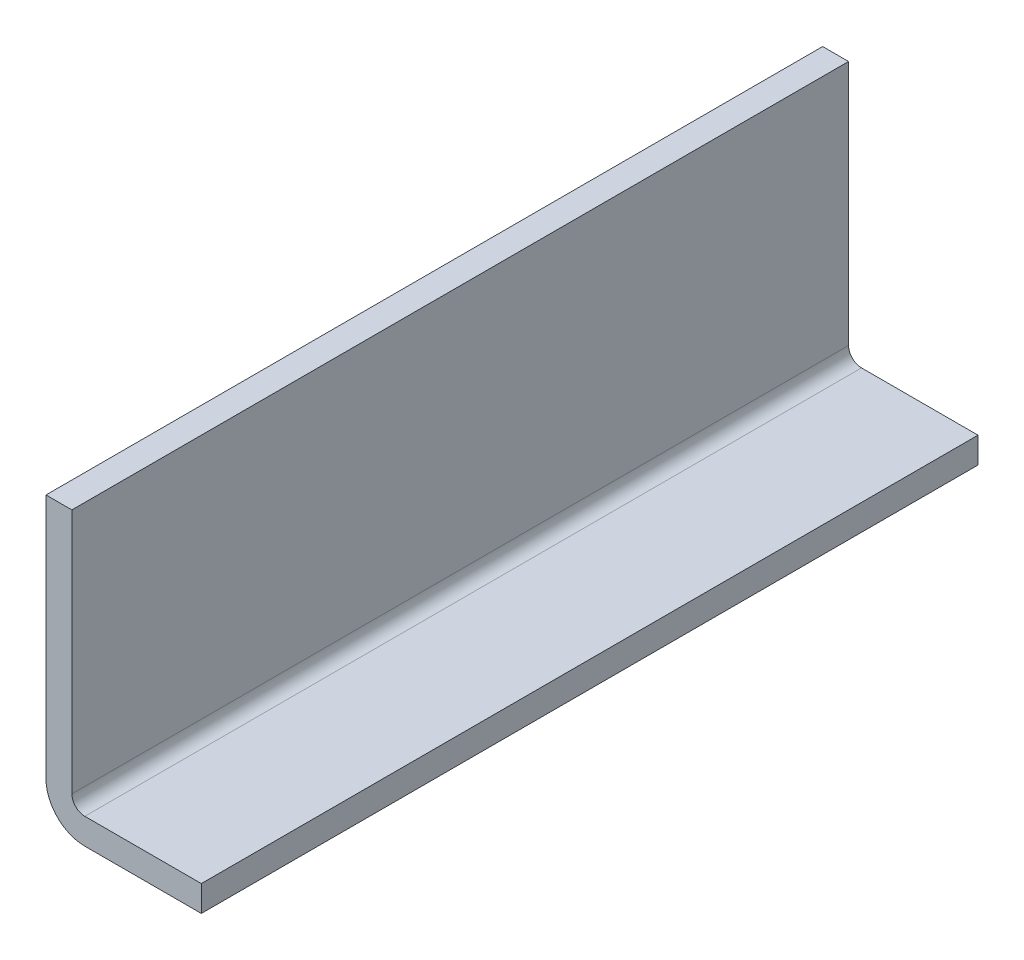
from build123d import *

# Parameters (mm, degrees)
EXTRUSION1_DEPTH = 60


with BuildPart() as part:
    # Esquisse1 → Extrusion1 (new body)
    with BuildSketch(Plane.XY):
        with BuildLine():
            Line((0, 20), (0, 1))
            ThreePointArc((0, 1), (0.292893219, 0.292893219), (1, 0))
            Line((1, 0), (10, 0))
            Line((10, 0), (10, -2))
            Line((10, -2), (1, -2))
            ThreePointArc((1, -2), (-1.121320344, -1.121320344), (-2, 1))
            Line((-2, 1), (-2, 20))
            Line((-2, 20), (0, 20))
        make_face()
    extrude(amount=EXTRUSION1_DEPTH)


solid = part.part
